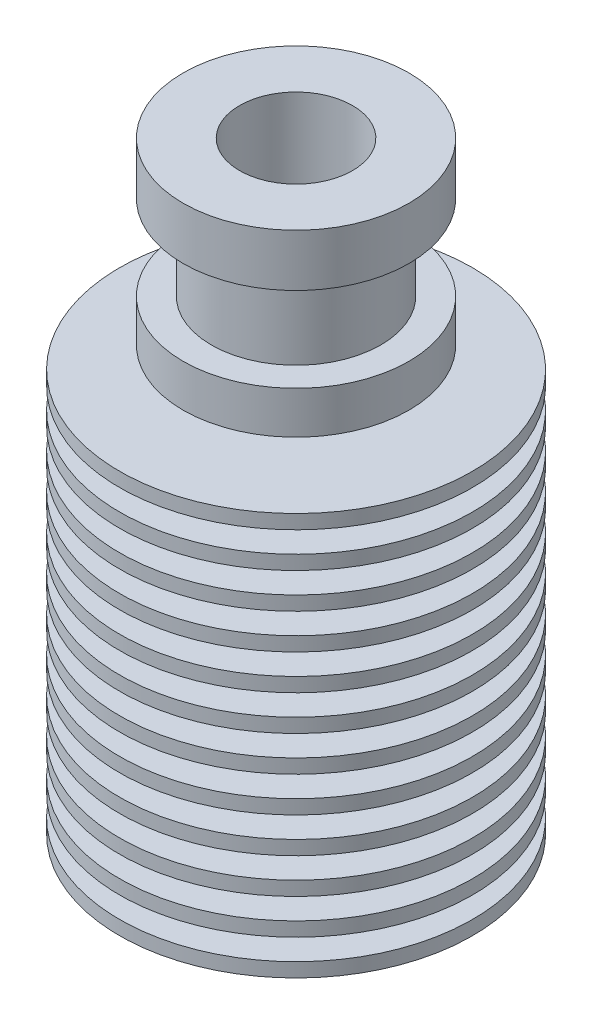
from build123d import *


with BuildPart() as part:
    # Sketch1 → Revolve1 (revolve)
    with BuildSketch(Plane.XY):
        Polygon((3.5, -21.35), (12.5, -21.35), (12.5, -20.35), (6.24, -20.35), (6.24, -18.85), (12.5, -18.85), (12.5, -17.85), (6.05575, -17.85), (6.05575, -16.35), (12.5, -16.35), (12.5, -15.35), (5.8715, -15.35), (5.8715, -13.85), (12.5, -13.85), (12.5, -12.85), (5.68725, -12.85), (5.68725, -11.35), (12.5, -11.35), (12.5, -10.35), (5.503, -10.35), (5.503, -8.85), (12.5, -8.85), (12.5, -7.85), (5.31875, -7.85), (5.31875, -6.35), (12.5, -6.35), (12.5, -5.35), (5.1345, -5.35), (5.1345, -3.85), (12.5, -3.85), (12.5, -2.85), (4.95025, -2.85), (4.95025, -1.35), (12.5, -1.35), (12.5, -0.35), (4.766, -0.35), (4.766, 1.15), (12.5, 1.15), (12.5, 2.15), (4.58175, 2.15), (4.58175, 3.65), (12.5, 3.65), (12.5, 4.65), (4.3975, 4.65), (4.3975, 6.15), (12.5, 6.15), (12.5, 7.15), (4.3975, 7.15), (4.3975, 8.65), (8, 8.65), (8, 11.65), (6, 11.65), (6, 17.65), (8, 17.65), (8, 21.35), (4, 21.35), (4, 11.35), (2.1, 10.253034489), (2.1, -5.741709623), (3.5, -6.55), align=None)
    revolve(axis=Axis((0, -21.35, 0), (0, 1, 0)))


solid = part.part
